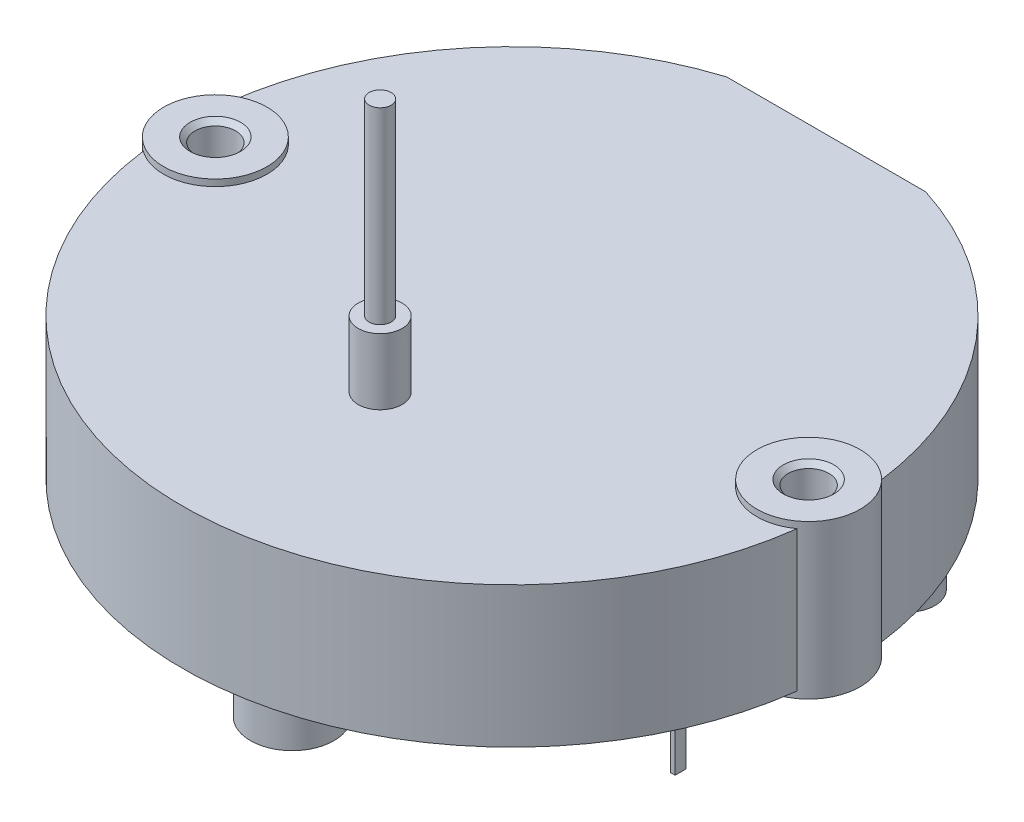
from build123d import *

# Parameters (mm, degrees)
BOSS_EXTRUDE1_DEPTH = 6.4
BOSS_EXTRUDE2_START = -6.7
SKETCH4_R           = 2.35
BOSS_EXTRUDE2_DEPTH = 7
SKETCH7_R           = 1.9
SKETCH7_R_2         = 1.25
BOSS_EXTRUDE3_DEPTH = 4.4
SKETCH8_W           = 0.2
SKETCH8_H           = 0.5
BOSS_EXTRUDE4_DEPTH = 3.9


with BuildPart() as part:
    # Sketch1 → Boss-Extrude1 (new body)
    with BuildSketch(Plane(origin=(0, 0, 0), x_dir=(1, 0, 0), z_dir=(0, 1, 0))):
        with BuildLine():
            Line((-4.52879675, 14.3), (4.52879675, 14.3))
            ThreePointArc((4.52879675, 14.3), (0, -15), (-4.52879675, 14.3))
        make_face()
    extrude(amount=BOSS_EXTRUDE1_DEPTH)

    # Sketch3 → Revolve1 (revolve)
    with BuildSketch(Plane.XY.offset(6)):
        Polygon((0, 17.95), (0.5, 17.95), (0.5, 9.4), (1, 9.4), (1, 6.4), (0, 6.4), align=None)
    revolve(axis=Axis((0, 6.4, 6), (0, 1, 0)))

    # Sketch4 → Boss-Extrude2 (add)
    with BuildSketch(Plane(origin=(0, 6.4, 0), x_dir=(1, 0, 0), z_dir=(0, 1, 0)).offset(BOSS_EXTRUDE2_START)):
        with Locations((-13.5, 0)):
            Circle(SKETCH4_R)
    boss_extrude2 = extrude(amount=BOSS_EXTRUDE2_DEPTH)

    # Sketch6 → Ø1.85 (1.85) Diameter Hole1 (revolve, cut)
    with BuildSketch(Plane(origin=(-13.5, -0.3, 0), x_dir=(0, 0, -1), z_dir=(1, 0, 0))):
        Polygon((0, 0), (0, 7), (1.15, 7), (0.925, 6.775), (0.925, 0.225), (1.15, 0), align=None)
    f_1_85_1_85_diameter_hole1 = revolve(axis=Axis((-13.5, -6.65, 0), (0, 1, 0)), mode=Mode.SUBTRACT)

    # Mirror1: Boss-Extrude2, Ø1.85 (1.85) Diameter Hole1 across plane
    add(boss_extrude2.mirror(Plane(origin=(0, 0, 0), x_dir=(0, 0, 1), z_dir=(1, 0, 0))))
    add(f_1_85_1_85_diameter_hole1.mirror(Plane(origin=(0, 0, 0), x_dir=(0, 0, 1), z_dir=(1, 0, 0))), mode=Mode.SUBTRACT)

    # Sketch7 → Boss-Extrude3 (add)
    with BuildSketch(Plane.XZ):
        with Locations((0, 10)):
            Circle(SKETCH7_R)
        with Locations((9, -9)):
            Circle(SKETCH7_R_2)
    extrude(amount=BOSS_EXTRUDE3_DEPTH)

    # Sketch8 → Boss-Extrude4 (add)
    with BuildSketch(Plane(origin=(0, 0, 0), x_dir=(-1, 0, 0), z_dir=(0, -1, 0))):
        with Locations((-11.425, -3.85)):
            Rectangle(SKETCH8_W, SKETCH8_H)
        with Locations((11.425, -3.85)):
            Rectangle(SKETCH8_W, SKETCH8_H)
        with Locations((-11.425, 3.85)):
            Rectangle(SKETCH8_W, SKETCH8_H)
        with Locations((11.425, 3.85)):
            Rectangle(SKETCH8_W, SKETCH8_H)
    extrude(amount=BOSS_EXTRUDE4_DEPTH)


solid = part.part
